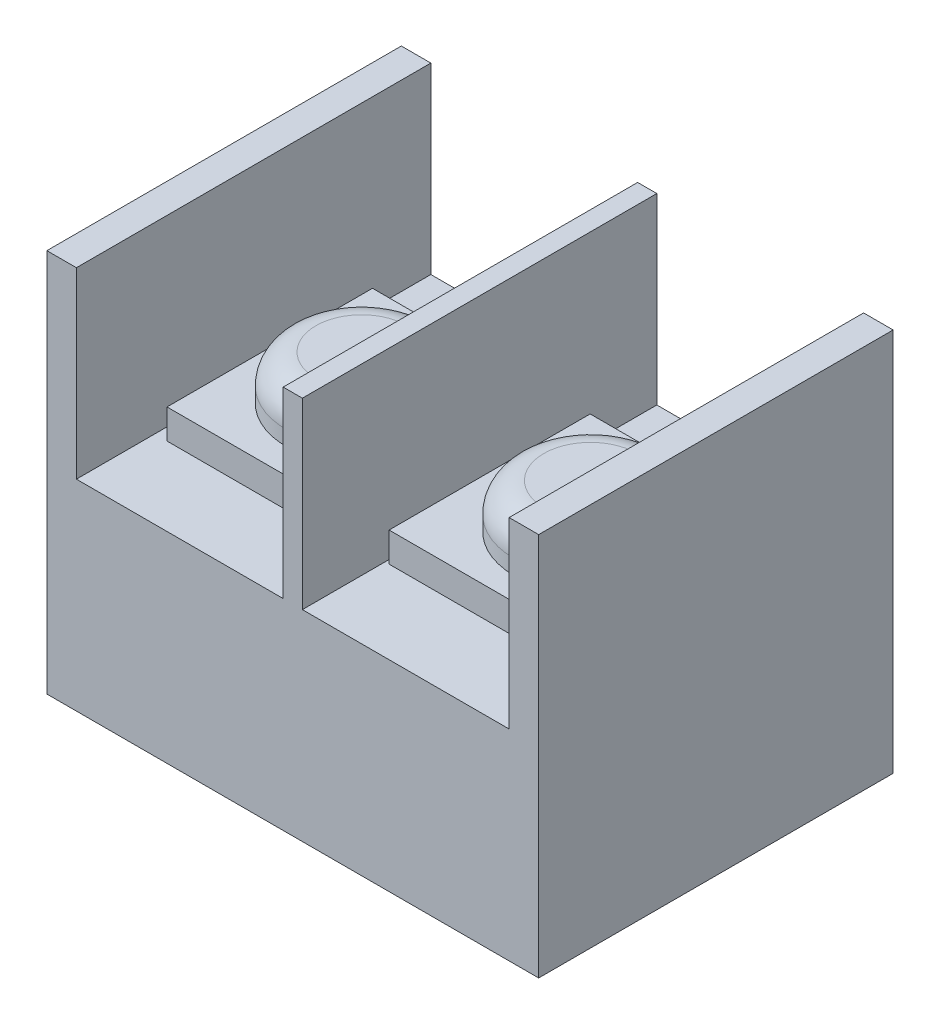
from build123d import *

# Parameters (mm, degrees)
SKETCH1_W           = 16.65
SKETCH1_H           = 12
BOSS_EXTRUDE1_DEPTH = 13
SKETCH2_W           = 7
SKETCH2_H           = 10.524951481
CUT_EXTRUDE1_DEPTH  = 13
SKETCH3_W           = 6.35563947
SKETCH3_H           = 6.957033312
SKETCH3_W_2         = 6.600584973
SKETCH3_H_2         = 6.806684851
BOSS_EXTRUDE2_DEPTH = 1
SKETCH4_R           = 2.546367572
SKETCH4_R_2         = 2.582102571
BOSS_EXTRUDE3_DEPTH = 1.5
FILLET1_R           = 1


with BuildPart() as part:
    # Sketch1 → Boss-Extrude1 (new body)
    with BuildSketch(Plane(origin=(0, 0, 0), x_dir=(1, 0, 0), z_dir=(0, 1, 0))):
        with Locations((-0.458958652, 0.629402757)):
            Rectangle(SKETCH1_W, SKETCH1_H)
    extrude(amount=BOSS_EXTRUDE1_DEPTH)

    # Sketch2 → Cut-Extrude1 (cut)
    with BuildSketch(Plane.XY.offset(5.370597243)):
        with Locations((-4.283958652, 12.062475741)):
            Rectangle(SKETCH2_W, SKETCH2_H)
        with Locations((3.366041348, 12.062475741)):
            Rectangle(SKETCH2_W, SKETCH2_H)
    extrude(amount=-CUT_EXTRUDE1_DEPTH, mode=Mode.SUBTRACT)

    # Sketch3 → Boss-Extrude2 (add)
    with BuildSketch(Plane(origin=(0, 6.8, 0), x_dir=(1, 0, 0), z_dir=(0, 1, 0))):
        with Locations((-4.190334083, 0.759249154)):
            Rectangle(SKETCH3_W, SKETCH3_H)
        with Locations((3.300292487, 0.834423384)):
            Rectangle(SKETCH3_W_2, SKETCH3_H_2)
    extrude(amount=BOSS_EXTRUDE2_DEPTH)

    # Sketch4 → Boss-Extrude3 (add)
    with BuildSketch(Plane(origin=(0, 7.8, 0), x_dir=(1, 0, 0), z_dir=(0, 1, 0))):
        with Locations((-4.183500062, 0.684074924)):
            Circle(SKETCH4_R)
        with Locations((3.456935343, 0.793419259)):
            Circle(SKETCH4_R_2)
    extrude(amount=BOSS_EXTRUDE3_DEPTH)

    # Fillet1
    fillet1_edges = [part.edges().sort_by_distance(p)[0] for p in [
        (-6.729867634, 9.3, -0.684074924),
        (0.874832772, 9.3, -0.793419259),
    ]]
    fillet(fillet1_edges, radius=FILLET1_R)


solid = part.part
